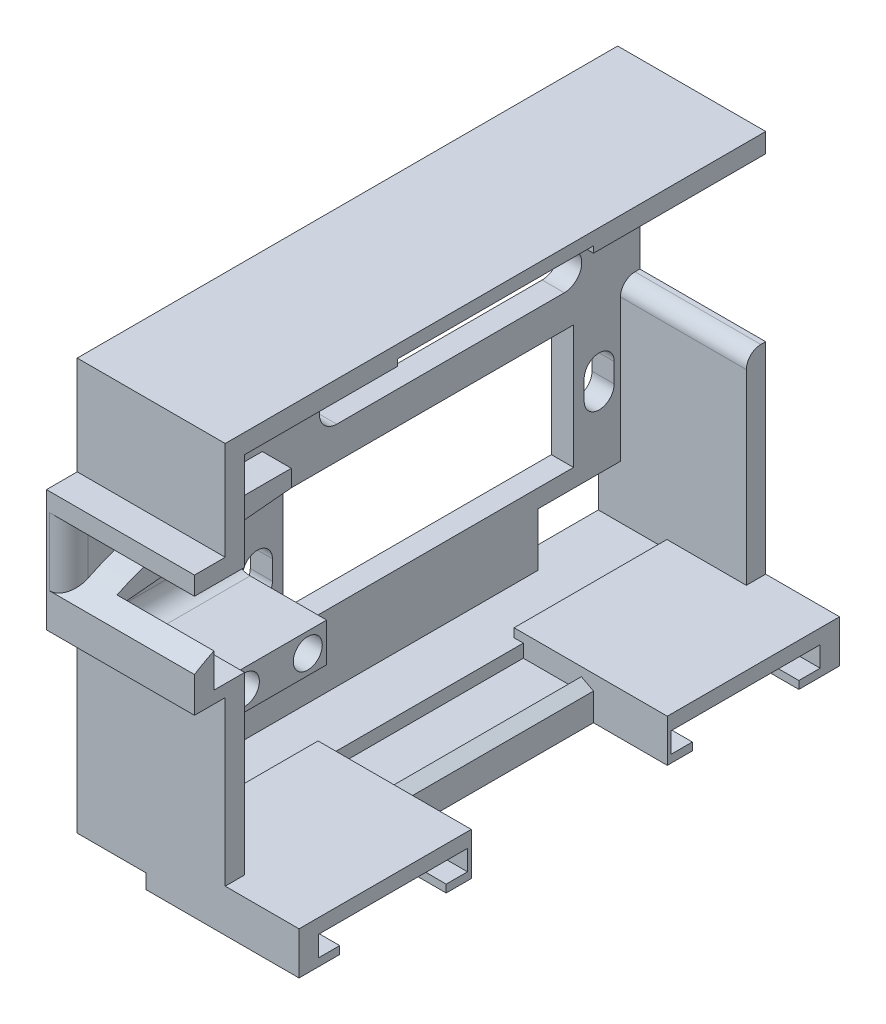
from build123d import *

# Parameters (mm, degrees)
MAIN_EXTRUDE_DEPTH            = 2.2875
WALLS_START                   = 2.2875
WALLS_DEPTH                   = 13
CORNER_SUPPORT_DEPTH          = 2
SKETCH2_R                     = 0.95
SKETCH2_W                     = 2.4
SKETCH2_H                     = 4
SKETCH2_W_2                   = 1
SWITCH_SPACER_DEPTH           = 9.9
ARM_SUPPORT_EXTRUDE_DEPTH     = 3
ARM_SUPPORT_CURVE_DEPTH       = 40.380356778
FILLET4_R                     = 2
FILLET3_R                     = 2
SKETCH2_5_R                   = 0.95
SWITCH_MOUNT_HOLES_DEPTH      = 40.380356889
SWITCH_MOUNT_HOLES_DEPTH_BACK = 40.380356889
SKETCH35_R                    = 1.5
SWITCH_MOUNT_EXIT_HOLES_DEPTH = 3
SKETCH4_W                     = 8.5
SKETCH4_H                     = 5.5
WIRE_HOLE_DEPTH               = 40.380356889
SKETCH25_W                    = 6
SKETCH25_H                    = 1.35
FEMALE_SNAP_DEPTH             = 10.125
SKETCH5_W                     = 30
SKETCH5_H                     = 12.75
SERVO_HOLE_DEPTH              = 40.380356889
SKETCH30_W                    = 15.7875
SKETCH30_H                    = 0.9
SKETCH30_W_2                  = 17.7875
SKETCH30_H_2                  = 1.5
MAGNET_EXTRUDE_1_DEPTH        = 7.625
MAGNET_EXTRUDE_1_DEPTH_BACK   = 8.2
SKETCH30_5_W                  = 20.25
SKETCH30_5_H                  = 1.5
MAGNET_EXTRUDE_2_DEPTH        = 8.2
SKETCH29_R                    = 7.7
MAGNET_HOLE_DEPTH             = 2.1
SKETCH31_R                    = 5.5
MAGNET_THRU_HOLE_DEPTH        = 58.632218961


with BuildPart() as part:
    # Sketch1 → Main Extrude (new body)
    with BuildSketch(Plane(origin=(0, 0, 0), x_dir=(0, 0, -1), z_dir=(1, 0, 0))):
        Polygon((-30.5, -1.48), (-27.325, -1.48), (-27.325, -21.25), (28.5, -21.25), (28.5, 21.25), (-27.325, 21.25), (-27.325, 11.07), (-30.5, 11.07), align=None)
        with BuildLine():
            Line((20.7, 4.22), (-2.8, 4.22))
            ThreePointArc((-2.8, 4.22), (-4.6, 6.02), (-2.8, 7.82))
            Line((-2.8, 7.82), (20.7, 7.82))
            ThreePointArc((20.7, 7.82), (22.5, 6.02), (20.7, 4.22))
        make_face(mode=Mode.SUBTRACT)
    extrude(amount=MAIN_EXTRUDE_DEPTH)

    # Sketch1_3 → Walls (add)
    with BuildSketch(Plane(origin=(0, 0, 0), x_dir=(0, 0, -1), z_dir=(1, 0, 0)).offset(WALLS_START)):
        Polygon((-25.325, 19.25), (28.5, 19.25), (28.5, 21.25), (-27.325, 21.25), (-27.325, 11.07), (-30.5, 11.07), (-30.5, 9.17), (-25.325, 9.17), align=None)
        with BuildLine():
            Line((28.5, 2.445), (28, 2.445))
            ThreePointArc((28, 2.445), (26.939339828, 2.005660172), (26.5, 0.945))
            Line((26.5, 0.945), (26.5, -19.25))
            Line((26.5, -19.25), (-25.325, -19.25))
            Line((-25.325, -19.25), (-25.325, -0.23))
            Line((-25.325, -0.23), (-28.5, -0.23))
            Line((-28.5, -0.23), (-28.5, 3.42))
            Line((-28.5, 3.42), (-30.5, 3.42))
            Line((-30.5, 3.42), (-30.5, -1.48))
            Line((-30.5, -1.48), (-27.325, -1.48))
            Line((-27.325, -1.48), (-27.325, -21.25))
            Line((-27.325, -21.25), (28.5, -21.25))
            Line((28.5, -21.25), (28.5, 2.445))
        make_face()
    extrude(amount=WALLS_DEPTH)

    # Sketch22 → Corner Support (add)
    with BuildSketch(Plane(origin=(0, 0, -28.5), x_dir=(-1, 0, 0), z_dir=(0, 0, -1))):
        Polygon((-4.2875, 19.25), (-2.2875, 18.25), (-2.2875, 19.25), align=None)
    extrude(amount=-CORNER_SUPPORT_DEPTH)

    # Sketch2 → Switch Spacer (add)
    with BuildSketch(Plane(origin=(2.2875, 0, 0), x_dir=(0, 0, -1), z_dir=(1, 0, 0))):
        Polygon((-14.75, -2.88), (-17.75, -2.88), (-17.75, -6.88), (-14.75, -6.88), (-14.75, -4.88), align=None)
        with Locations((-15.7, -4.88)):
            Circle(SKETCH2_R, mode=Mode.SUBTRACT)
        with Locations((-15.7, -4.88)):
            Circle(SKETCH2_R)
        Polygon((-20.15, -2.88), (-23.15, -2.88), (-23.15, -4.88), (-23.15, -6.88), (-20.15, -6.88), align=None)
        with BuildLine():
            ThreePointArc((-21.25, -4.88), (-22.2, -5.83), (-23.15, -4.88))
            ThreePointArc((-23.15, -4.88), (-22.2, -3.93), (-21.25, -4.88))
        make_face(mode=Mode.SUBTRACT)
        with Locations((-22.2, -4.88)):
            Circle(SKETCH2_R)
        Polygon((-23.15, -4.88), (-23.15, -2.88), (-25.325, -2.88), (-25.325, -6.88), (-23.15, -6.88), align=None)
        with Locations((-18.95, -4.88)):
            Rectangle(SKETCH2_W, SKETCH2_H)
        with Locations((-14.25, -4.88)):
            Rectangle(SKETCH2_W_2, SKETCH2_H)
    extrude(amount=SWITCH_SPACER_DEPTH)

    # Sketch3 → Arm Support Extrude (add)
    with BuildSketch(Plane(origin=(2.2875, 0, 0), x_dir=(0, 0, -1), z_dir=(1, 0, 0))):
        with BuildLine():
            Line((-18.5, 5.62), (-10.5, 5.62))
            Line((-10.5, 5.62), (-10.5, 3.87))
            Line((-10.5, 3.87), (-28.5, 2.17))
            Line((-28.5, 2.17), (-30.5, 2.17))
            ThreePointArc((-30.5, 2.17), (-24.743046131, 4.740377849), (-18.5, 5.62))
        make_face()
    extrude(amount=ARM_SUPPORT_EXTRUDE_DEPTH)

    # Sketch7 → Arm Support Curve (cut, through all)
    with BuildSketch(Plane(origin=(2.2875, 0, 0), x_dir=(0, 0, -1), z_dir=(1, 0, 0))):
        with BuildLine():
            Line((-28.5, 3.286589176), (-28.5, 3.42))
            Line((-28.5, 3.42), (-30.5, 3.42))
            Line((-30.5, 3.42), (-30.5, 2.17))
            ThreePointArc((-30.5, 2.17), (-29.627655409, 2.689861102), (-28.73283292, 3.17))
            ThreePointArc((-28.73283292, 3.17), (-28.616584416, 3.228630003), (-28.5, 3.286589176))
        make_face()
    extrude(amount=ARM_SUPPORT_CURVE_DEPTH, mode=Mode.SUBTRACT)

    # Fillet4
    fillet4_edges = [part.edges().sort_by_distance(p)[0] for p in [
        (2.2875, 5.67, 30.5),
    ]]
    fillet(fillet4_edges, radius=FILLET4_R)

    # Fillet3
    fillet3_edges = [part.edges().sort_by_distance(p)[0] for p in [
        (2.2875, -6.88, 19.5375),
        (2.2875, -2.88, 19.5375),
    ]]
    fillet(fillet3_edges, radius=FILLET3_R)

    # Sketch2_5 → Switch Mount Holes (cut, two sides)
    with BuildSketch(Plane(origin=(2.2875, 0, 0), x_dir=(0, 0, -1), z_dir=(1, 0, 0))) as switch_mount_holes_sk:
        with Locations((-22.2, -4.88)):
            Circle(SKETCH2_5_R)
        with Locations((-15.7, -4.88)):
            Circle(SKETCH2_5_R)
    extrude(amount=SWITCH_MOUNT_HOLES_DEPTH, mode=Mode.SUBTRACT)
    extrude(switch_mount_holes_sk.sketch, amount=-SWITCH_MOUNT_HOLES_DEPTH_BACK, mode=Mode.SUBTRACT)

    # Sketch35 → Switch Mount Exit Holes (cut)
    with BuildSketch(Plane(origin=(12.1875, 0, 0), x_dir=(0, 0, -1), z_dir=(1, 0, 0))):
        with Locations((-22.2, -4.88)):
            Circle(SKETCH35_R)
        with Locations((-15.7, -4.88)):
            Circle(SKETCH35_R)
    extrude(amount=-SWITCH_MOUNT_EXIT_HOLES_DEPTH, mode=Mode.SUBTRACT)

    # Sketch4 → Wire Hole (cut, through all)
    with BuildSketch(Plane(origin=(2.2875, 0, 0), x_dir=(0, 0, -1), z_dir=(1, 0, 0))):
        with Locations((22.25, -16.5)):
            Rectangle(SKETCH4_W, SKETCH4_H)
    extrude(amount=-WIRE_HOLE_DEPTH, mode=Mode.SUBTRACT)

    # Sketch25 → Female Snap (cut, symmetric)
    with BuildSketch(Plane(origin=(0, 0, -0.5875), x_dir=(-1, 0, 0), z_dir=(0, 0, -1))):
        with Locations((-11.0375, -19.925)):
            Rectangle(SKETCH25_W, SKETCH25_H)
        Polygon((-15.2875, -19.25), (-15.2875, -19.91463679), (-14.0375, -19.25), align=None)
        with Locations((-11.0375, 19.925)):
            Rectangle(SKETCH25_W, SKETCH25_H)
        Polygon((-15.2875, 19.91463679), (-15.2875, 19.25), (-14.0375, 19.25), align=None)
    extrude(amount=FEMALE_SNAP_DEPTH, both=True, mode=Mode.SUBTRACT)

    # Sketch5 → Servo Hole (cut, through all)
    with BuildSketch(Plane(origin=(2.2875, 0, 0), x_dir=(0, 0, -1), z_dir=(1, 0, 0))):
        with Locations((6.65, -5.505)):
            Rectangle(SKETCH5_W, SKETCH5_H)
        with BuildLine():
            Line((-9.45, -4.505), (-9.45, -6.505))
            ThreePointArc((-9.45, -6.505), (-11, -8.055), (-12.55, -6.505))
            Line((-12.55, -6.505), (-12.55, -4.505))
            ThreePointArc((-12.55, -4.505), (-11, -2.955), (-9.45, -4.505))
        make_face()
        with BuildLine():
            Line((25.85, -4.505), (25.85, -6.505))
            ThreePointArc((25.85, -6.505), (24.3, -8.055), (22.75, -6.505))
            Line((22.75, -6.505), (22.75, -4.505))
            ThreePointArc((22.75, -4.505), (24.3, -2.955), (25.85, -4.505))
        make_face()
    extrude(amount=-SERVO_HOLE_DEPTH, mode=Mode.SUBTRACT)

    # Sketch30 → Magnet Extrude 1 (add, two sides)
    with BuildSketch(Plane(origin=(15.2875, 0, 0), x_dir=(0, 0, -1), z_dir=(1, 0, 0))) as magnet_extrude_1_sk:
        Polygon((-27.325, -18.35), (-27.325, -21.25), (-9.5375, -21.25), (-9.5375, -19.91463679), (-9.5375, -19.25), (-25.325, -19.25), (-25.325, -18.35), align=None)
        with Locations((-17.43125, -18.8)):
            Rectangle(SKETCH30_W, SKETCH30_H)
        with Locations((19.60625, -22)):
            Rectangle(SKETCH30_W_2, SKETCH30_H_2)
        Polygon((10.7125, -19.91463679), (10.7125, -21.25), (28.5, -21.25), (28.5, -18.35), (26.5, -18.35), (26.5, -19.25), (10.7125, -19.25), align=None)
        with Locations((-18.43125, -22)):
            Rectangle(SKETCH30_W_2, SKETCH30_H_2)
        with Locations((18.60625, -18.8)):
            Rectangle(SKETCH30_W, SKETCH30_H)
    extrude(amount=MAGNET_EXTRUDE_1_DEPTH)
    extrude(magnet_extrude_1_sk.sketch, amount=-MAGNET_EXTRUDE_1_DEPTH_BACK)

    # Sketch30_5 → Magnet Extrude 2 (add)
    with BuildSketch(Plane(origin=(15.2875, 0, 0), x_dir=(0, 0, -1), z_dir=(1, 0, 0))):
        with Locations((0.5875, -22)):
            Rectangle(SKETCH30_5_W, SKETCH30_5_H)
    extrude(amount=-MAGNET_EXTRUDE_2_DEPTH)

    # Sketch29 → Magnet Hole (cut)
    with BuildSketch(Plane(origin=(0, -21.95, 0), x_dir=(1, 0, 0), z_dir=(0, 1, 0))):
        with Locations((15.2875, -17.625)):
            Circle(SKETCH29_R)
        with BuildLine():
            ThreePointArc((22.9125, -18.697089082), (20.338980677, -23.436414885), (15.2875, -25.325))
            Line((15.2875, -25.325), (22.9125, -25.325))
            Line((22.9125, -25.325), (22.9125, -18.697089082))
        make_face()
        with BuildLine():
            Line((22.9125, -9.925), (15.2875, -9.925))
            ThreePointArc((15.2875, -9.925), (20.338980677, -11.813585115), (22.9125, -16.552910918))
            Line((22.9125, -16.552910918), (22.9125, -9.925))
        make_face()
        with Locations((15.2875, 18.8)):
            Circle(SKETCH29_R)
        with BuildLine():
            ThreePointArc((22.9125, 17.727910918), (20.338980677, 12.988585115), (15.2875, 11.1))
            Line((15.2875, 11.1), (22.9125, 11.1))
            Line((22.9125, 11.1), (22.9125, 17.727910918))
        make_face()
        with BuildLine():
            Line((22.9125, 26.5), (15.2875, 26.5))
            ThreePointArc((15.2875, 26.5), (20.338980677, 24.611414885), (22.9125, 19.872089082))
            Line((22.9125, 19.872089082), (22.9125, 26.5))
        make_face()
        with BuildLine():
            ThreePointArc((22.9875, -17.625), (22.968727116, -17.087645368), (22.9125, -16.552910918))
            Line((22.9125, -16.552910918), (22.9125, -18.697089082))
            ThreePointArc((22.9125, -18.697089082), (22.968727116, -18.162354632), (22.9875, -17.625))
        make_face()
        with BuildLine():
            Line((22.9125, 19.872089082), (22.9125, 17.727910918))
            ThreePointArc((22.9125, 17.727910918), (22.968727116, 18.262645368), (22.9875, 18.8))
            ThreePointArc((22.9875, 18.8), (22.968727116, 19.337354632), (22.9125, 19.872089082))
        make_face()
    extrude(amount=MAGNET_HOLE_DEPTH, mode=Mode.SUBTRACT)

    # Sketch31 → Magnet Thru Hole (cut, through all)
    with BuildSketch(Plane.XZ.offset(21.95)):
        with Locations((15.2875, 17.625)):
            Circle(SKETCH31_R)
        with BuildLine():
            Line((22.9125, 23.125), (15.2875, 23.125))
            ThreePointArc((15.2875, 23.125), (19.176587297, 21.514087297), (20.7875, 17.625))
            ThreePointArc((20.7875, 17.625), (19.176587297, 13.735912703), (15.2875, 12.125))
            Line((15.2875, 12.125), (22.9125, 12.125))
            Line((22.9125, 12.125), (22.9125, 23.125))
        make_face()
        with Locations((15.2875, -18.8)):
            Circle(SKETCH31_R)
        with BuildLine():
            Line((22.9125, -13.3), (15.2875, -13.3))
            ThreePointArc((15.2875, -13.3), (19.176587297, -14.910912703), (20.7875, -18.8))
            ThreePointArc((20.7875, -18.8), (19.176587297, -22.689087297), (15.2875, -24.3))
            Line((15.2875, -24.3), (22.9125, -24.3))
            Line((22.9125, -24.3), (22.9125, -13.3))
        make_face()
    extrude(amount=MAGNET_THRU_HOLE_DEPTH, mode=Mode.SUBTRACT)


solid = part.part
